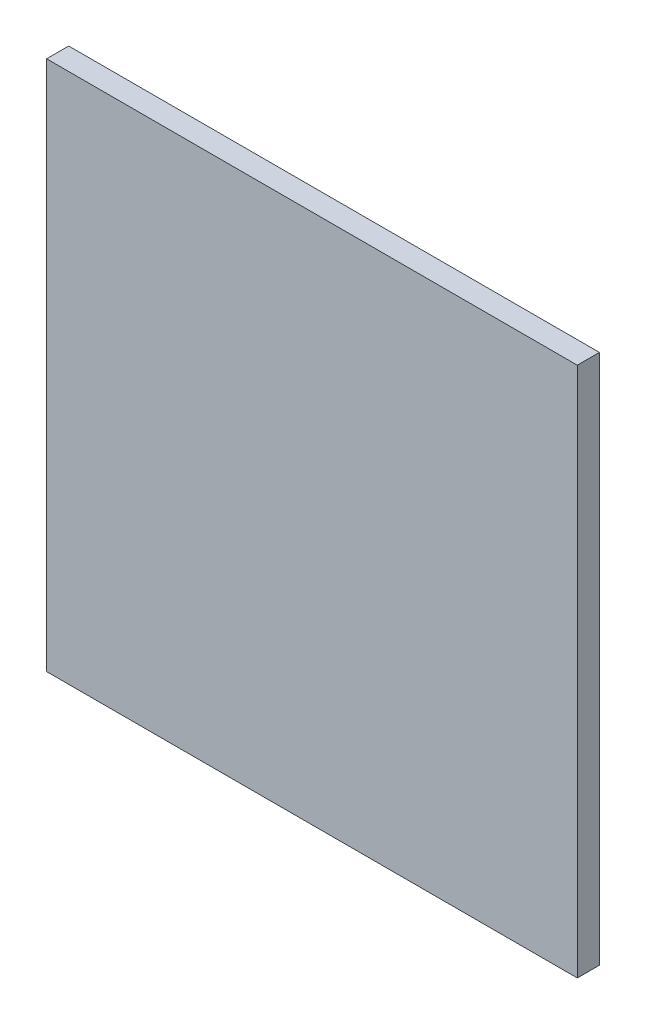
from build123d import *

# Parameters (mm, degrees)
SKETCH1_W           = 304.8
SKETCH1_H           = 304.8
BOSS_EXTRUDE1_DEPTH = 12.7


with BuildPart() as part:
    # Sketch1 → Boss-Extrude1 (new body)
    with BuildSketch(Plane.XY):
        with Locations((-60.739130435, 60.186956522)):
            Rectangle(SKETCH1_W, SKETCH1_H)
    extrude(amount=BOSS_EXTRUDE1_DEPTH)


solid = part.part
